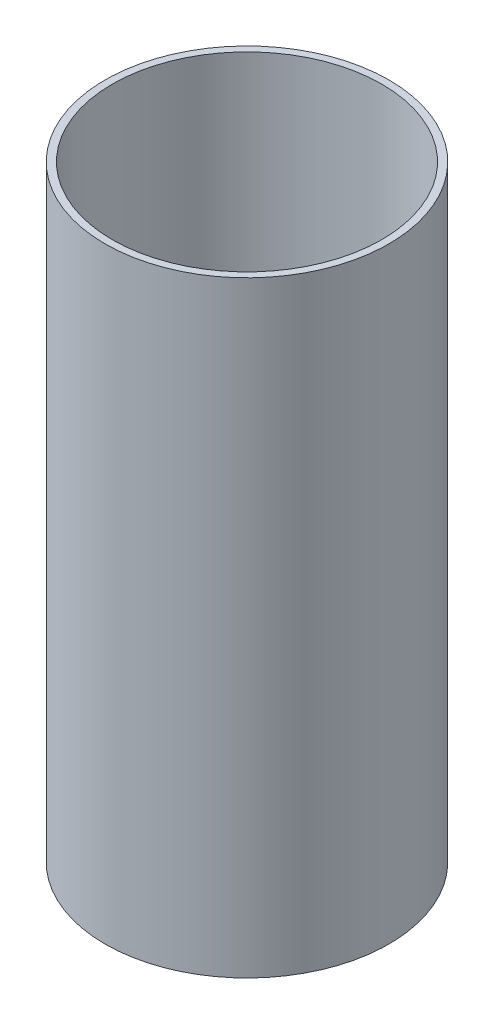
from build123d import *

# Parameters (mm, degrees)
SKETCH1_R           = 93.6625
SKETCH1_R_2         = 88.9
BOSS_EXTRUDE1_DEPTH = 200.025


with BuildPart() as part:
    # Sketch1 → Boss-Extrude1 (new body, symmetric)
    with BuildSketch(Plane(origin=(0, 0, 0), x_dir=(1, 0, 0), z_dir=(0, 1, 0))):
        Circle(SKETCH1_R)
        Circle(SKETCH1_R_2, mode=Mode.SUBTRACT)
    extrude(amount=BOSS_EXTRUDE1_DEPTH, both=True)


solid = part.part
